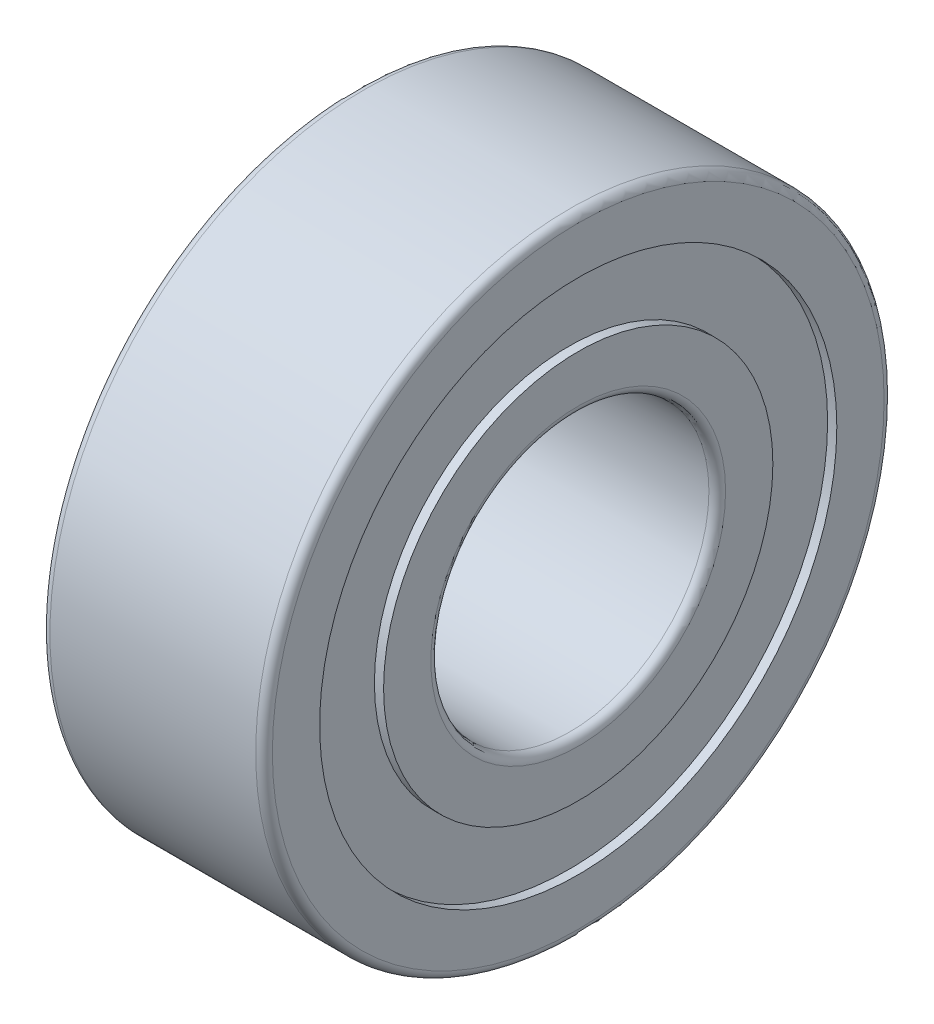
from build123d import *


with BuildPart() as part:
    # Sketch1 → Revolve1 (revolve)
    with BuildSketch(Plane.XY):
        with BuildLine():
            Line((0, 3.5), (0, 2.65))
            ThreePointArc((0, 2.65), (0.043933983, 2.543933983), (0.15, 2.5))
            Line((0.15, 2.5), (3.85, 2.5))
            ThreePointArc((3.85, 2.5), (3.956066017, 2.543933983), (4, 2.65))
            Line((4, 2.65), (4, 3.5))
            Line((4, 3.5), (3.8345, 3.5))
            Line((3.8345, 3.5), (3.8345, 4.65))
            Line((3.8345, 4.65), (4, 4.65))
            Line((4, 4.65), (4, 5.5))
            ThreePointArc((4, 5.5), (3.956066017, 5.606066017), (3.85, 5.65))
            Line((3.85, 5.65), (0.15, 5.65))
            ThreePointArc((0.15, 5.65), (0.043933983, 5.606066017), (0, 5.5))
            Line((0, 5.5), (0, 4.65))
            Line((0, 4.65), (0.1655, 4.65))
            Line((0.1655, 4.65), (0.1655, 3.5))
            Line((0.1655, 3.5), (0, 3.5))
        make_face()
    revolve(axis=Axis((-0.0025, 0, 0), (1, 0, 0)))


solid = part.part
